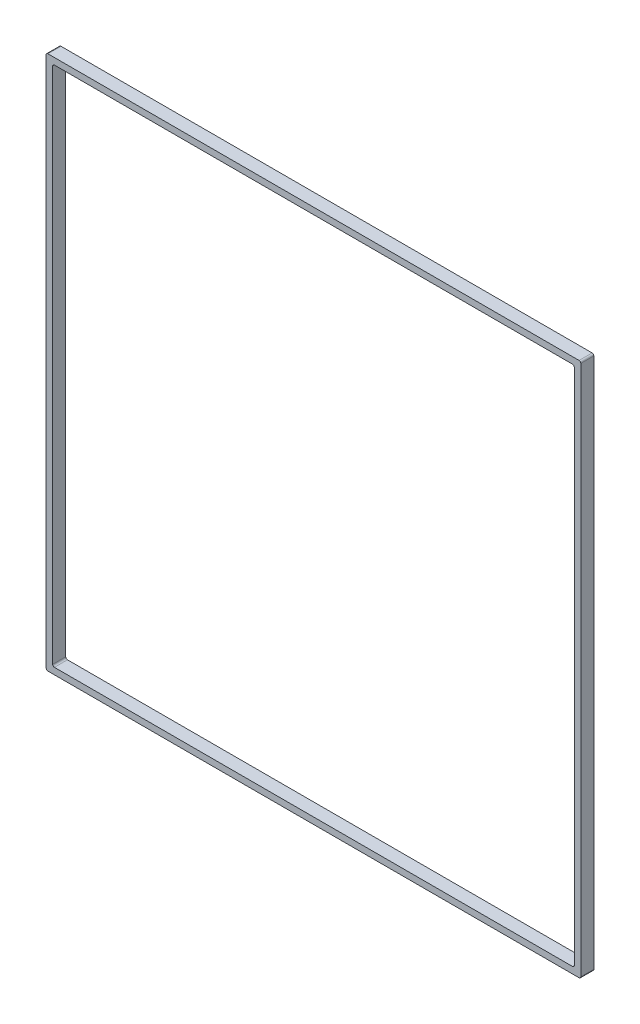
from build123d import *

# Parameters (mm, degrees)
SKETCH1_W           = 781.05
SKETCH1_H           = 781.05
SKETCH1_W_2         = 762
SKETCH1_H_2         = 762
BOSS_EXTRUDE1_DEPTH = 19.05
FILLET1_R           = 2.54


with BuildPart() as part:
    # Sketch1 → Boss-Extrude1 (new body)
    with BuildSketch(Plane.XY):
        Rectangle(SKETCH1_W, SKETCH1_H)
        Rectangle(SKETCH1_W_2, SKETCH1_H_2, mode=Mode.SUBTRACT)
    extrude(amount=BOSS_EXTRUDE1_DEPTH)

    # Fillet1
    fillet1_edges = [part.edges().sort_by_distance(p)[0] for p in [
        (381, -381, 9.525),
        (381, 381, 9.525),
        (-381, 381, 9.525),
        (-381, -381, 9.525),
        (390.525, -390.525, 9.525),
        (-390.525, -390.525, 9.525),
        (-390.525, 390.525, 9.525),
        (390.525, 390.525, 9.525),
    ]]
    fillet(fillet1_edges, radius=FILLET1_R)


solid = part.part
